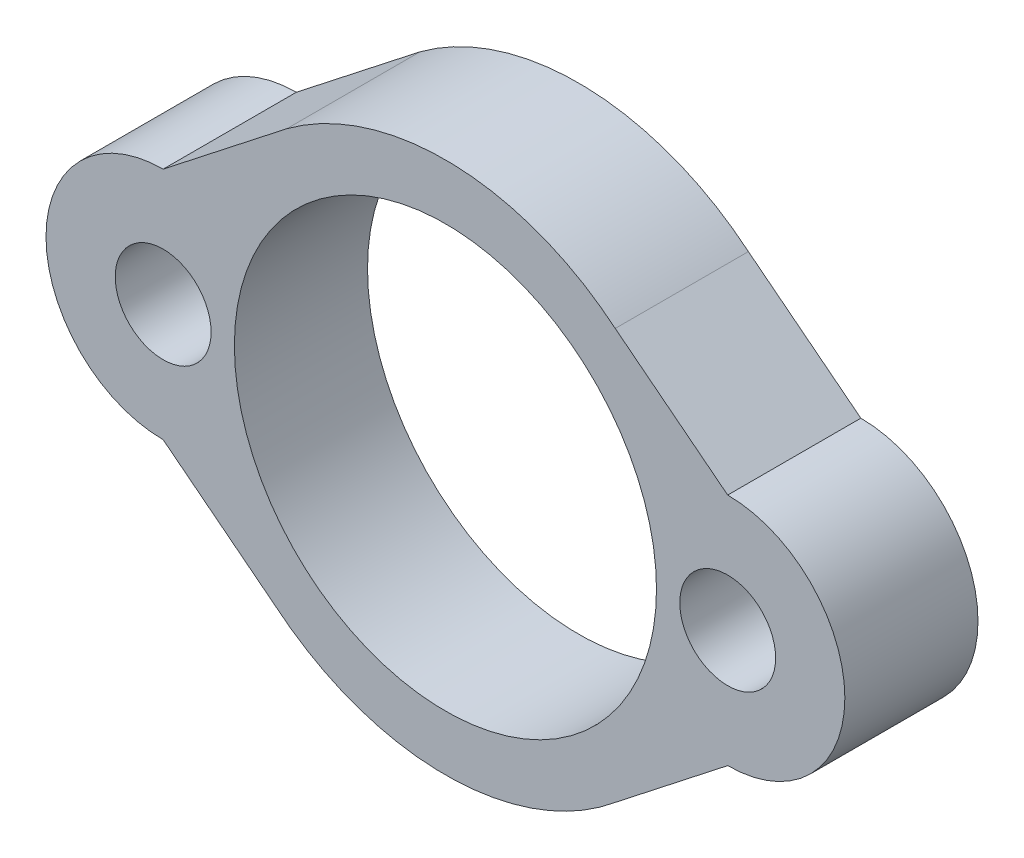
from build123d import *

# Parameters (mm, degrees)
SKETCH1_R           = 1.143
SKETCH1_R_2         = 5.0330227
BOSS_EXTRUDE1_DEPTH = 3.175


with BuildPart() as part:
    # Sketch1 → Boss-Extrude1 (new body)
    with BuildSketch(Plane.XY):
        with BuildLine():
            Line((-2.758483637, 1.414768622), (-5.574053245, -0.790421797))
            ThreePointArc((-5.574053245, -0.790421797), (-8.368053245, -3.584421797), (-5.574053245, -6.378421797))
            Line((-5.574053245, -6.378421797), (-2.89267695, -8.478510283))
            ThreePointArc((-2.89267695, -8.478510283), (1.156946755, -9.936709122), (5.206570461, -8.478510283))
            Line((5.206570461, -8.478510283), (7.887946755, -6.378421797))
            ThreePointArc((7.887946755, -6.378421797), (10.681946755, -3.584421797), (7.887946755, -0.790421797))
            Line((7.887946755, -0.790421797), (5.206570461, 1.309666689))
            ThreePointArc((5.206570461, 1.309666689), (1.327399862, 2.765578203), (-2.624290324, 1.519870555))
            Line((-2.624290324, 1.519870555), (-2.758483637, 1.414768622))
        make_face()
        with Locations((7.887946755, -3.584421797)):
            Circle(SKETCH1_R, mode=Mode.SUBTRACT)
        with Locations((-5.574053245, -3.584421797)):
            Circle(SKETCH1_R, mode=Mode.SUBTRACT)
        with Locations((1.156946755, -3.584421797)):
            Circle(SKETCH1_R_2, mode=Mode.SUBTRACT)
    extrude(amount=BOSS_EXTRUDE1_DEPTH)


solid = part.part
